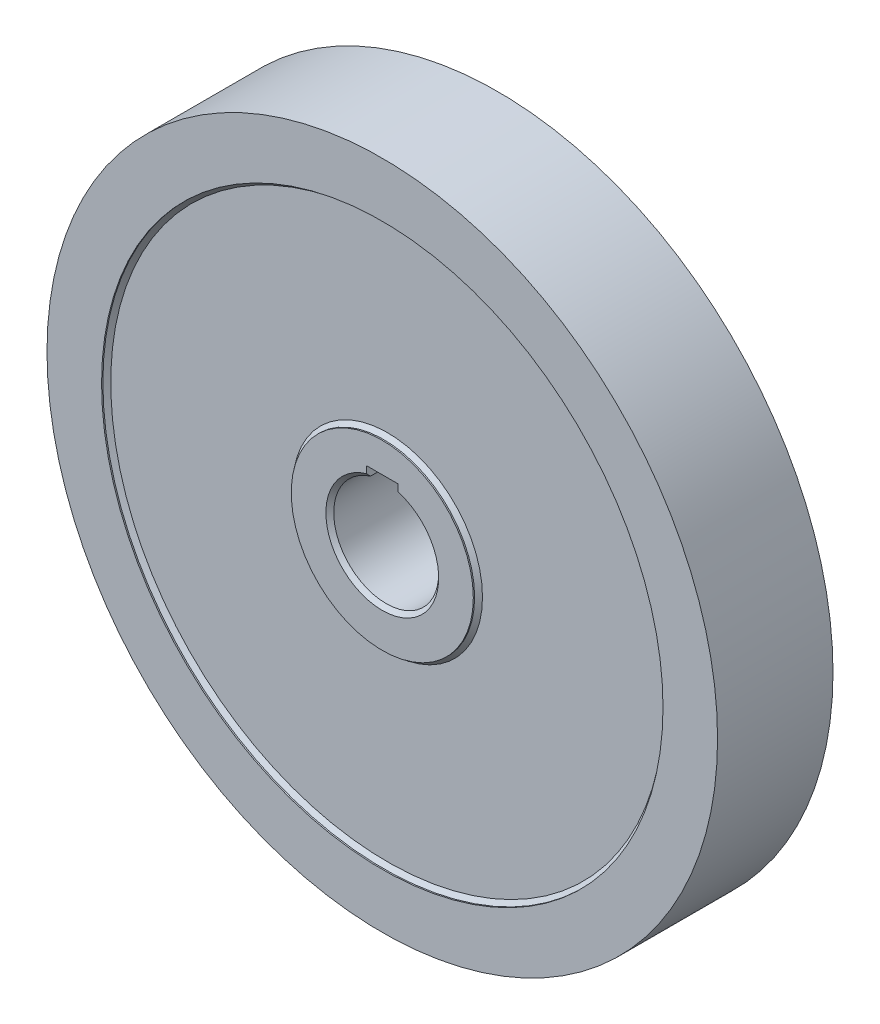
from build123d import *

# Parameters (mm, degrees)
SKETCH3_R               = 127.8
BOSS_EXTRUDE1_DEPTH     = 22
CUT_EXTRUDE1_DEPTH      = 1
CUT_EXTRUDE1_DEPTH_BACK = 45
SKETCH7_R               = 107
SKETCH7_R_2             = 34.7
CUT_EXTRUDE2_DEPTH      = 2
CHAMFER1_SIZE           = 1.5
CHAMFER2_SIZE           = 1.5
CHAMFER3_SIZE           = 1.5
CHAMFER4_SIZE           = 1.5


with BuildPart() as part:
    # Sketch3 → Boss-Extrude1 (new body, symmetric)
    with BuildSketch(Plane.XY):
        Circle(SKETCH3_R)
    extrude(amount=BOSS_EXTRUDE1_DEPTH, both=True)

    # Sketch6 → Cut-Extrude1 (cut, two sides)
    with BuildSketch(Plane.XY.offset(22)) as cut_extrude1_sk:
        with BuildLine():
            Line((-6, 19.078784028), (-6, 23.3))
            Line((-6, 23.3), (6, 23.3))
            Line((6, 23.3), (6, 19.078784028))
            ThreePointArc((6, 19.078784028), (0, -20), (-6, 19.078784028))
        make_face()
    extrude(amount=CUT_EXTRUDE1_DEPTH, mode=Mode.SUBTRACT)
    extrude(cut_extrude1_sk.sketch, amount=-CUT_EXTRUDE1_DEPTH_BACK, mode=Mode.SUBTRACT)

    # Sketch7 → Cut-Extrude2 (cut)
    with BuildSketch(Plane.XY.offset(22)):
        Circle(SKETCH7_R)
        Circle(SKETCH7_R_2, mode=Mode.SUBTRACT)
    cut_extrude2 = extrude(amount=-CUT_EXTRUDE2_DEPTH, mode=Mode.SUBTRACT)

    # Mirror1: Cut-Extrude2 across plane
    add(cut_extrude2.mirror(Plane.XY), mode=Mode.SUBTRACT)

    # Chamfer1
    chamfer1_edges = [part.edges().sort_by_distance(p)[0] for p in [
        (-107, 0, 20),
    ]]
    chamfer(chamfer1_edges, length=CHAMFER1_SIZE)

    # Chamfer2
    chamfer2_edges = [part.edges().sort_by_distance(p)[0] for p in [
        (-34.7, 0, 20),
    ]]
    chamfer(chamfer2_edges, length=CHAMFER2_SIZE)

    # Chamfer3
    chamfer3_edges = [part.edges().sort_by_distance(p)[0] for p in [
        (0, -20, 22),
    ]]
    chamfer(chamfer3_edges, length=CHAMFER3_SIZE)

    # Chamfer4
    chamfer4_edges = [part.edges().sort_by_distance(p)[0] for p in [
        (0, -20, -22),
        (-107, 0, -20),
        (-34.7, 0, -20),
    ]]
    chamfer(chamfer4_edges, length=CHAMFER4_SIZE)


solid = part.part
